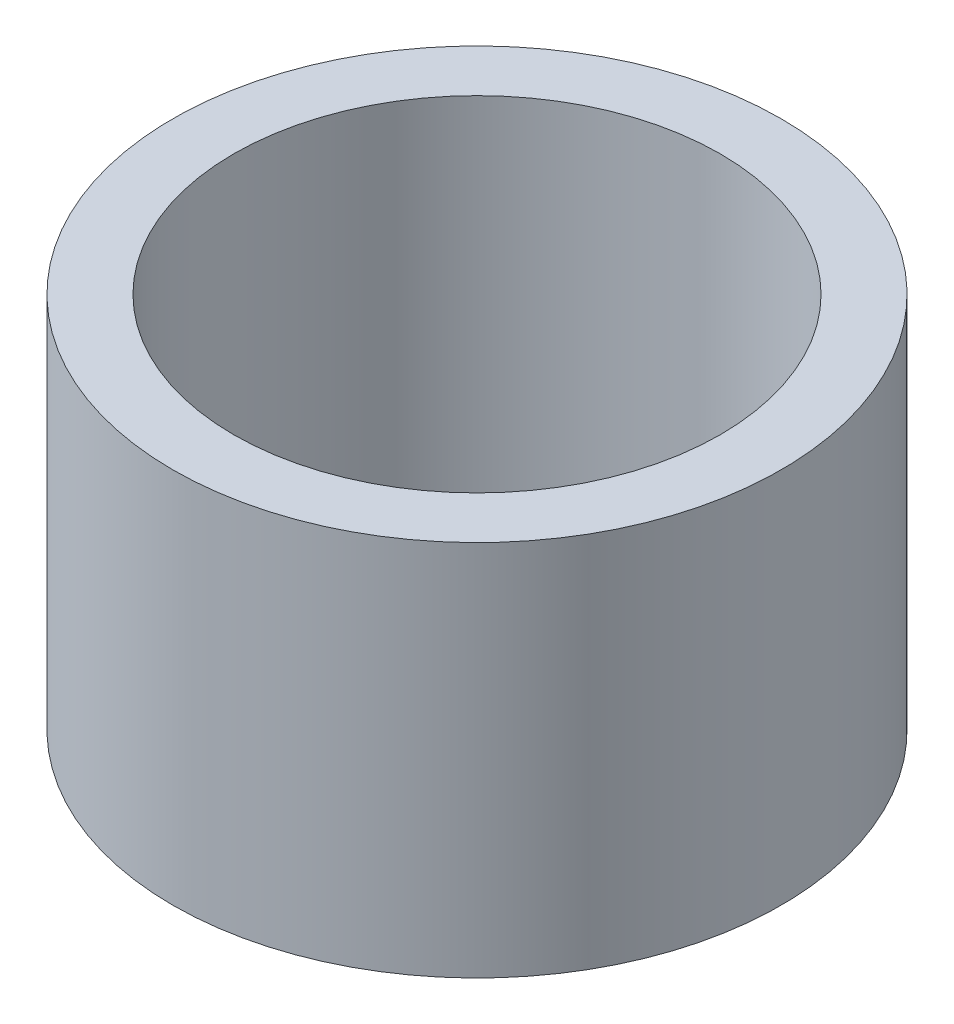
from build123d import *

# Parameters (mm, degrees)
SKETCH1_R           = 7.9375
SKETCH1_R_2         = 6.35
BOSS_EXTRUDE1_DEPTH = 9.8425


with BuildPart() as part:
    # Sketch1 → Boss-Extrude1 (new body)
    with BuildSketch(Plane(origin=(0, 0, 0), x_dir=(1, 0, 0), z_dir=(0, 1, 0))):
        Circle(SKETCH1_R)
        Circle(SKETCH1_R_2, mode=Mode.SUBTRACT)
    extrude(amount=BOSS_EXTRUDE1_DEPTH)


solid = part.part
